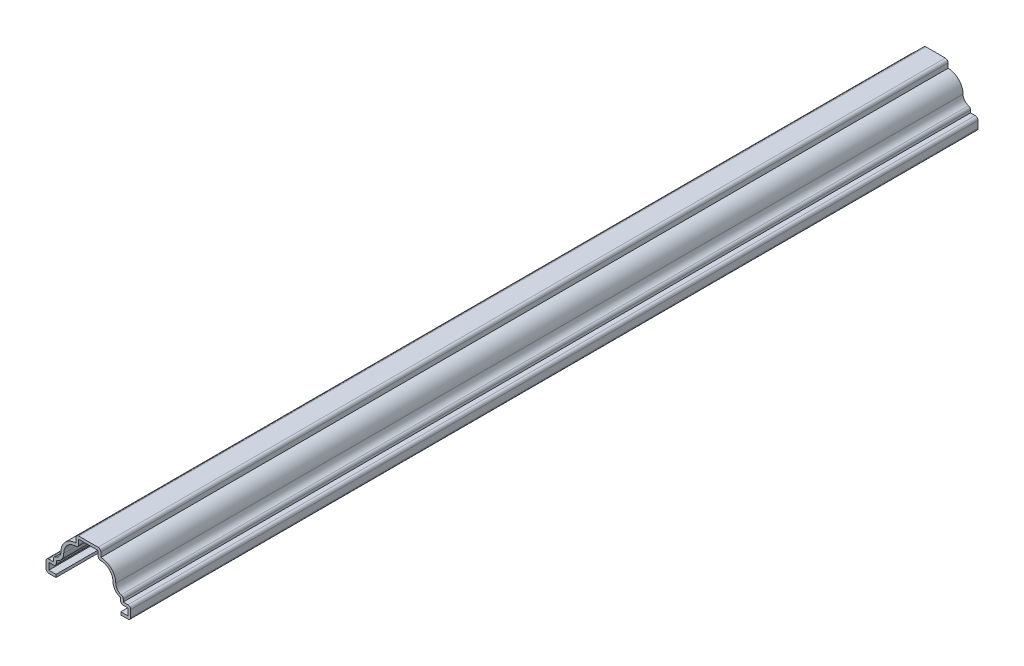
from build123d import *

# Parameters (mm, degrees)
EXTRUDE_THIN1_DEPTH = 269.875
FILLET1_R           = 0.889


with BuildPart() as part:
    # Sketch1 → Extrude-Thin1 (new body)
    with BuildSketch(Plane.XY):
        with BuildLine():
            Line((10.31875, 0), (13.49375, 0))
            Line((13.49375, 0), (13.49375, 3.96875))
            Line((13.49375, 3.96875), (11.1125, 3.96875))
            Line((11.1125, 3.96875), (11.1125, 5.55625))
            ThreePointArc((11.1125, 5.55625), (9.428701977, 6.253701977), (8.73125, 7.9375))
            ThreePointArc((8.73125, 7.9375), (7.336346045, 11.305096045), (3.96875, 12.7))
            Line((3.96875, 12.7), (3.96875, 15.08125))
            Line((3.96875, 15.08125), (-3.96875, 15.08125))
            Line((-3.96875, 15.08125), (-3.96875, 12.7))
            ThreePointArc((-3.96875, 12.7), (-7.336346045, 11.305096045), (-8.73125, 7.9375))
            ThreePointArc((-8.73125, 7.9375), (-9.428701977, 6.253701977), (-11.1125, 5.55625))
            Line((-11.1125, 5.55625), (-11.1125, 3.96875))
            Line((-11.1125, 3.96875), (-13.49375, 3.96875))
            Line((-13.49375, 3.96875), (-13.49375, 0))
            Line((-13.49375, 0), (-10.31875, 0))
            Line((-10.31875, 0), (-10.31875, 0.889))
            Line((-10.31875, 0.889), (-12.60475, 0.889))
            Line((-12.60475, 0.889), (-12.60475, 3.07975))
            Line((-12.60475, 3.07975), (-10.2235, 3.07975))
            Line((-10.2235, 3.07975), (-10.2235, 4.790403868))
            ThreePointArc((-10.2235, 4.790403868), (-8.504647693, 5.96426879), (-7.84225, 7.9375))
            ThreePointArc((-7.84225, 7.9375), (-6.372960967, 10.974566327), (-3.07975, 11.707603613))
            Line((-3.07975, 11.707603613), (-3.07975, 14.19225))
            Line((-3.07975, 14.19225), (3.07975, 14.19225))
            Line((3.07975, 14.19225), (3.07975, 11.707603613))
            ThreePointArc((3.07975, 11.707603613), (6.372960967, 10.974566327), (7.84225, 7.9375))
            ThreePointArc((7.84225, 7.9375), (8.504647693, 5.96426879), (10.2235, 4.790403868))
            Line((10.2235, 4.790403868), (10.2235, 3.07975))
            Line((10.2235, 3.07975), (12.60475, 3.07975))
            Line((12.60475, 3.07975), (12.60475, 0.889))
            Line((12.60475, 0.889), (10.31875, 0.889))
            Line((10.31875, 0.889), (10.31875, 0))
        make_face()
    extrude(amount=-EXTRUDE_THIN1_DEPTH)

    # Fillet1
    fillet1_edges = [part.edges().sort_by_distance(p)[0] for p in [
        (-13.49375, 0, -134.9375),
        (-13.49375, 3.96875, -134.9375),
        (-11.1125, 5.55625, -134.9375),
        (-3.96875, 15.08125, -134.9375),
        (3.96875, 15.08125, -134.9375),
        (11.1125, 5.55625, -134.9375),
        (13.49375, 3.96875, -134.9375),
        (13.49375, 0, -134.9375),
        (10.2235, 3.07975, -134.9375),
        (3.07975, 11.707603613, -134.9375),
        (-3.07975, 11.707603613, -134.9375),
        (-10.2235, 3.07975, -134.9375),
    ]]
    fillet(fillet1_edges, radius=FILLET1_R)


solid = part.part
